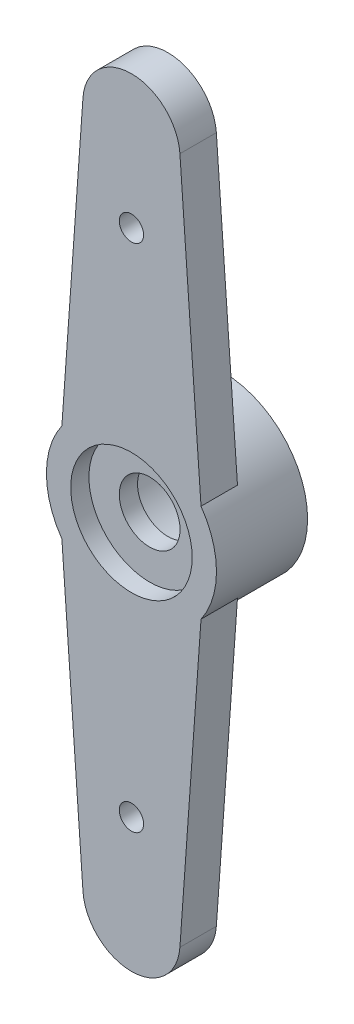
from build123d import *

# Parameters (mm, degrees)
SKETCH1_R           = 1.2499975
BOSS_EXTRUDE1_DEPTH = 1.5
SKETCH2_R           = 0.5
CUT_EXTRUDE1_DEPTH  = 1.5
SKETCH4_R           = 3.5
SKETCH4_R_2         = 2.5
BOSS_EXTRUDE2_DEPTH = 2.25
SKETCH5_R           = 2.5
SKETCH5_R_2         = 1.2499975
CUT_EXTRUDE2_DEPTH  = 0.75


with BuildPart() as part:
    # Sketch1 → Boss-Extrude1 (new body)
    with BuildSketch(Plane.XY):
        with BuildLine():
            Line((-1.994891435, 14.142857143), (-2.863567464, 2.012456554))
            ThreePointArc((-2.863567464, 2.012456554), (-3.5, 0), (-2.863567464, -2.012456554))
            Line((-2.863567464, -2.012456554), (-1.994891435, -14.142857143))
            ThreePointArc((-1.994891435, -14.142857143), (0, -16), (1.994891435, -14.142857143))
            Line((1.994891435, -14.142857143), (2.863567464, -2.012456554))
            ThreePointArc((2.863567464, -2.012456554), (3.5, 0), (2.863567464, 2.012456554))
            Line((2.863567464, 2.012456554), (1.994891435, 14.142857143))
            ThreePointArc((1.994891435, 14.142857143), (0, 16), (-1.994891435, 14.142857143))
        make_face()
        Circle(SKETCH1_R, mode=Mode.SUBTRACT)
    extrude(amount=BOSS_EXTRUDE1_DEPTH)

    # Sketch2 → Cut-Extrude1 (cut)
    with BuildSketch(Plane.XY.offset(1.5)):
        with Locations((0, 10.5)):
            Circle(SKETCH2_R)
        with Locations((0, -10.5)):
            Circle(SKETCH2_R)
    extrude(amount=-CUT_EXTRUDE1_DEPTH, mode=Mode.SUBTRACT)

    # Sketch4 → Boss-Extrude2 (add)
    with BuildSketch(Plane(origin=(0, 0, 0), x_dir=(-1, 0, 0), z_dir=(0, 0, -1))):
        Circle(SKETCH4_R)
        Circle(SKETCH4_R_2, mode=Mode.SUBTRACT)
    extrude(amount=BOSS_EXTRUDE2_DEPTH)

    # Sketch5 → Cut-Extrude2 (cut)
    with BuildSketch(Plane.XY.offset(1.5)):
        Circle(SKETCH5_R)
        Circle(SKETCH5_R_2, mode=Mode.SUBTRACT)
    extrude(amount=-CUT_EXTRUDE2_DEPTH, mode=Mode.SUBTRACT)


solid = part.part
